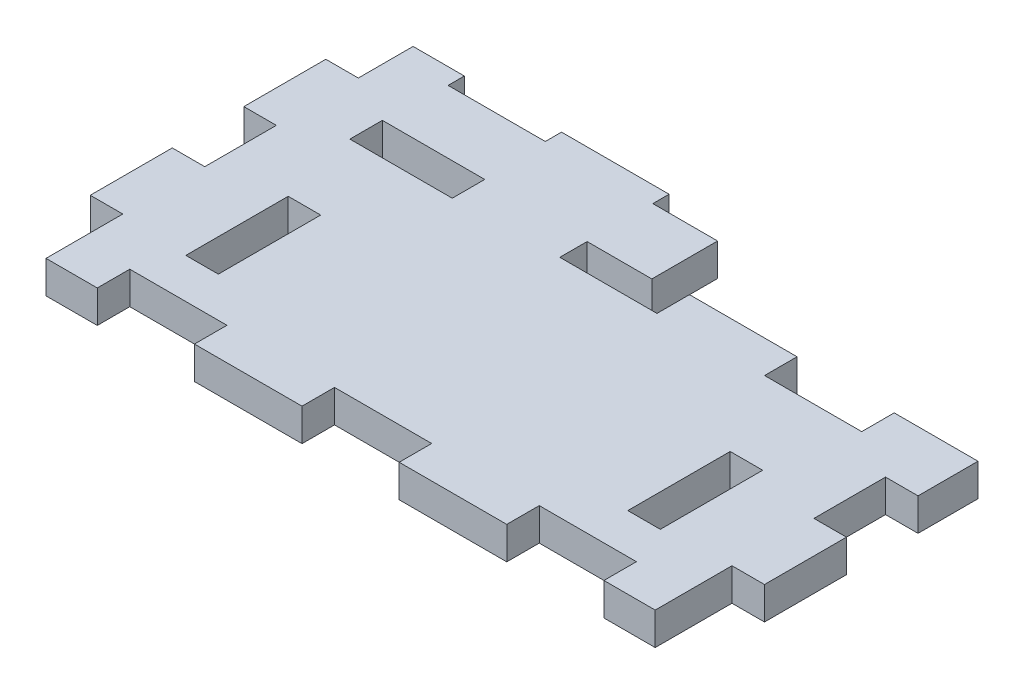
from build123d import *

# Parameters (mm, degrees)
SKETCH1_W           = 65.35
SKETCH1_H           = 35.35
BOSS_EXTRUDE1_DEPTH = 3.175
SKETCH2_W           = 28.175
SKETCH2_H           = 7.5
CUT_EXTRUDE1_DEPTH  = 4.175
SKETCH3_W           = 10
SKETCH3_H           = 3.175
SKETCH3_W_2         = 3.175
SKETCH3_H_2         = 7.5
SKETCH3_H_3         = 5.9125
SKETCH3_H_4         = 5.35
SKETCH3_H_5         = 1.5875
CUT_EXTRUDE2_DEPTH  = 3.175
SKETCH7_W           = 3.175
SKETCH7_H           = 10
CUT_EXTRUDE3_DEPTH  = 4.175
BOSS_EXTRUDE2_DEPTH = 3.175


with BuildPart() as part:
    # Sketch1 → Boss-Extrude1 (new body)
    with BuildSketch(Plane(origin=(0, 0, 0), x_dir=(1, 0, 0), z_dir=(0, 1, 0))):
        with Locations((32.675, 17.675)):
            Rectangle(SKETCH1_W, SKETCH1_H)
    extrude(amount=BOSS_EXTRUDE1_DEPTH)

    # Sketch2 → Cut-Extrude1 (cut, through all)
    with BuildSketch(Plane.XZ):
        with Locations((51.2625, -31.6)):
            Rectangle(SKETCH2_W, SKETCH2_H)
    extrude(amount=-CUT_EXTRUDE1_DEPTH, mode=Mode.SUBTRACT)

    # Sketch3 → Cut-Extrude2 (cut)
    with BuildSketch(Plane.XZ):
        with Locations((52.675, -1.5875)):
            Rectangle(SKETCH3_W, SKETCH3_H)
        with Locations((63.7625, -3.75)):
            Rectangle(SKETCH3_W_2, SKETCH3_H_2)
        with Locations((63.7625, -18.75)):
            Rectangle(SKETCH3_W_2, SKETCH3_H_2)
        with Locations((52.675, -26.2625)):
            Rectangle(SKETCH3_W, SKETCH3_H)
        Polygon((37.175, -27.85), (37.675, -27.85), (37.675, -24.675), (27.675, -24.675), (27.675, -27.85), (34, -27.85), align=None)
        with Locations((35.5875, -30.80625)):
            Rectangle(SKETCH3_W_2, SKETCH3_H_3)
        Polygon((37.175, -35.35), (37.175, -33.7625), (34, -33.7625), (27.675, -33.7625), (27.675, -35.35), align=None)
        with Locations((12.675, -26.2625)):
            Rectangle(SKETCH3_W, SKETCH3_H)
        with Locations((1.5875, -32.675)):
            Rectangle(SKETCH3_W_2, SKETCH3_H_4)
        with Locations((1.5875, -18.75)):
            Rectangle(SKETCH3_W_2, SKETCH3_H_2)
        with Locations((1.5875, -3.75)):
            Rectangle(SKETCH3_W_2, SKETCH3_H_2)
        with Locations((12.675, -1.5875)):
            Rectangle(SKETCH3_W, SKETCH3_H)
        with Locations((32.675, -1.5875)):
            Rectangle(SKETCH3_W, SKETCH3_H)
        with Locations((12.675, -34.55625)):
            Rectangle(SKETCH3_W, SKETCH3_H_5)
    extrude(amount=-CUT_EXTRUDE2_DEPTH, mode=Mode.SUBTRACT)

    # Sketch7 → Cut-Extrude3 (cut, through all)
    with BuildSketch(Plane.XZ):
        with Locations((11.0875, -11.825)):
            Rectangle(SKETCH7_W, SKETCH7_H)
        with Locations((54.2625, -11.825)):
            Rectangle(SKETCH7_W, SKETCH7_H)
    extrude(amount=-CUT_EXTRUDE3_DEPTH, mode=Mode.SUBTRACT)

    # Sketch6 → Boss-Extrude2 (add)
    with BuildSketch(Plane(origin=(0, 3.175, 0), x_dir=(1, 0, 0), z_dir=(0, 1, 0))):
        Polygon((7.929, -0.254), (7.929, 2.921), (17.421, 2.921), (17.421, -0.254), (27.929, -0.254), (27.929, 2.921), (37.421, 2.921), (37.421, -0.254), (47.929, -0.254), (47.929, 2.921), (57.421, 2.921), (57.421, -0.254), (62.429, -0.254), (62.429, 7.246), (65.604, 7.246), (65.604, 15.254), (62.429, 15.254), (62.429, 22.246), (65.604, 22.246), (65.604, 28.104), (57.421, 28.104), (57.421, 24.929), (47.929, 24.929), (47.929, 28.104), (37.421, 28.104), (37.421, 24.929), (27.929, 24.929), (27.929, 27.596), (34.254, 27.596), (34.254, 34.0165), (27.929, 34.0165), (27.929, 35.604), (17.421, 35.604), (17.421, 34.0165), (7.929, 34.0165), (7.929, 35.604), (2.921, 35.604), (2.921, 30.254), (-0.254, 30.254), (-0.254, 22.246), (2.921, 22.246), (2.921, 15.254), (-0.254, 15.254), (-0.254, 7.246), (2.921, 7.246), (2.921, -0.254), align=None)
        Polygon((6.675, 4.175), (18.675, 4.175), (18.675, 1), (26.675, 1), (26.675, 4.175), (38.675, 4.175), (38.675, 1), (46.675, 1), (46.675, 4.175), (58.675, 4.175), (58.675, 1), (61.175, 1), (61.175, 8.5), (64.35, 8.5), (64.35, 14), (61.175, 14), (61.175, 23.5), (64.35, 23.5), (64.35, 26.85), (58.675, 26.85), (58.675, 23.675), (46.675, 23.675), (46.675, 26.85), (38.675, 26.85), (38.675, 23.675), (26.675, 23.675), (26.675, 28.85), (33, 28.85), (33, 32.7625), (26.675, 32.7625), (26.675, 34.35), (18.675, 34.35), (18.675, 32.7625), (6.675, 32.7625), (6.675, 34.35), (4.175, 34.35), (4.175, 29), (1, 29), (1, 23.5), (4.175, 23.5), (4.175, 14), (1, 14), (1, 8.5), (4.175, 8.5), (4.175, 1), (6.675, 1), align=None, mode=Mode.SUBTRACT)
    extrude(amount=-BOSS_EXTRUDE2_DEPTH)


solid = part.part
